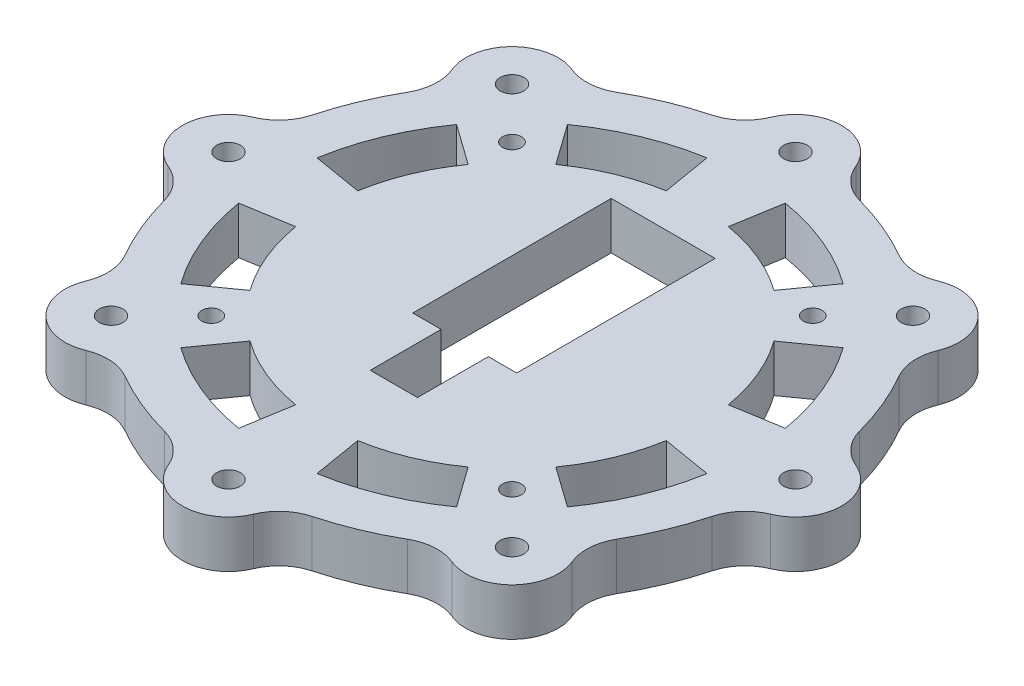
from build123d import *

# Parameters (mm, degrees)
CROQUIS1_W              = 22
CROQUIS1_H              = 42
CROQUIS1_R              = 2.5
CROQUIS1_R_2            = 2
SALIENTE_EXTRUIR1_DEPTH = 10
REDONDEO1_R             = 10
CROQUIS2_R              = 5
CORTAR_EXTRUIR1_DEPTH   = 5
CROQUIS3_W              = 10
CROQUIS3_H              = 15
CORTAR_EXTRUIR2_DEPTH   = 10


with BuildPart() as part:
    # Croquis1 → Saliente-Extruir1 (new body)
    with BuildSketch(Plane(origin=(0, 0, 0), x_dir=(1, 0, 0), z_dir=(0, 1, 0))):
        with BuildLine():
            ThreePointArc((-34.99474883, -48.737742606), (-22.961005942, -55.432771951), (-9.717764093, -59.2078125))
            ThreePointArc((-9.717764093, -59.2078125), (0, -69.75), (9.717764093, -59.2078125))
            ThreePointArc((9.717764093, -59.2078125), (22.961005942, -55.432771951), (34.99474883, -48.737742606))
            ThreePointArc((34.99474883, -48.737742606), (49.320697988, -49.320697988), (48.737742606, -34.99474883))
            ThreePointArc((48.737742606, -34.99474883), (55.432771951, -22.961005942), (59.2078125, -9.717764093))
            ThreePointArc((59.2078125, -9.717764093), (69.75, 0), (59.2078125, 9.717764093))
            ThreePointArc((59.2078125, 9.717764093), (55.432771951, 22.961005942), (48.737742606, 34.99474883))
            ThreePointArc((48.737742606, 34.99474883), (49.320697988, 49.320697988), (34.99474883, 48.737742606))
            ThreePointArc((34.99474883, 48.737742606), (22.961005942, 55.432771951), (9.717764093, 59.2078125))
            ThreePointArc((9.717764093, 59.2078125), (0, 69.75), (-9.717764093, 59.2078125))
            ThreePointArc((-9.717764093, 59.2078125), (-22.961005942, 55.432771951), (-34.99474883, 48.737742606))
            ThreePointArc((-34.99474883, 48.737742606), (-49.320697988, 49.320697988), (-48.737742606, 34.99474883))
            ThreePointArc((-48.737742606, 34.99474883), (-55.432771951, 22.961005942), (-59.2078125, 9.717764093))
            ThreePointArc((-59.2078125, 9.717764093), (-69.75, 0), (-59.2078125, -9.717764093))
            ThreePointArc((-59.2078125, -9.717764093), (-55.432771951, -22.961005942), (-48.737742606, -34.99474883))
            ThreePointArc((-48.737742606, -34.99474883), (-49.320697988, -49.320697988), (-34.99474883, -48.737742606))
        make_face()
        with Locations((0, 11)):
            Rectangle(CROQUIS1_W, CROQUIS1_H, mode=Mode.SUBTRACT)
        with BuildLine():
            Line((6.560642333, 39.204852661), (8.293642194, 49.560851477))
            ThreePointArc((8.293642194, 49.560851477), (19.229842476, 46.424946509), (29.180323524, 40.909304797))
            Line((29.180323524, 40.909304797), (23.08294249, 32.361091855))
            ThreePointArc((23.08294249, 32.361091855), (15.211666437, 36.724211417), (6.560642333, 39.204852661))
        make_face(mode=Mode.SUBTRACT)
        with BuildLine():
            Line((-8.293642194, 49.560851477), (-6.560642333, 39.204852661))
            ThreePointArc((-6.560642333, 39.204852661), (-15.211666437, 36.724211417), (-23.08294249, 32.361091855))
            Line((-23.08294249, 32.361091855), (-29.180323524, 40.909304797))
            ThreePointArc((-29.180323524, 40.909304797), (-19.229842476, 46.424946509), (-8.293642194, 49.560851477))
        make_face(mode=Mode.SUBTRACT)
        with BuildLine():
            Line((-40.909304797, 29.180323524), (-32.361091855, 23.08294249))
            ThreePointArc((-32.361091855, 23.08294249), (-36.724211417, 15.211666437), (-39.204852661, 6.560642333))
            Line((-39.204852661, 6.560642333), (-49.560851477, 8.293642194))
            ThreePointArc((-49.560851477, 8.293642194), (-46.424946509, 19.229842476), (-40.909304797, 29.180323524))
        make_face(mode=Mode.SUBTRACT)
        with Locations((-42.426406871, -42.426406871)):
            Circle(CROQUIS1_R, mode=Mode.SUBTRACT)
        with Locations((-42.426406871, 42.426406871)):
            Circle(CROQUIS1_R, mode=Mode.SUBTRACT)
        with Locations((-60, 0)):
            Circle(CROQUIS1_R, mode=Mode.SUBTRACT)
        with Locations((0, -60)):
            Circle(CROQUIS1_R, mode=Mode.SUBTRACT)
        with Locations((42.426406871, -42.426406871)):
            Circle(CROQUIS1_R, mode=Mode.SUBTRACT)
        with Locations((60, 0)):
            Circle(CROQUIS1_R, mode=Mode.SUBTRACT)
        with Locations((42.426406871, 42.426406871)):
            Circle(CROQUIS1_R, mode=Mode.SUBTRACT)
        with Locations((0, 60)):
            Circle(CROQUIS1_R, mode=Mode.SUBTRACT)
        with BuildLine():
            Line((-49.560851477, -8.293642194), (-39.204852661, -6.560642333))
            ThreePointArc((-39.204852661, -6.560642333), (-36.724211417, -15.211666437), (-32.361091855, -23.08294249))
            Line((-32.361091855, -23.08294249), (-40.909304797, -29.180323524))
            ThreePointArc((-40.909304797, -29.180323524), (-46.424946509, -19.229842476), (-49.560851477, -8.293642194))
        make_face(mode=Mode.SUBTRACT)
        with BuildLine():
            Line((-29.180323524, -40.909304797), (-23.08294249, -32.361091855))
            ThreePointArc((-23.08294249, -32.361091855), (-15.211666437, -36.724211417), (-6.560642333, -39.204852661))
            Line((-6.560642333, -39.204852661), (-8.293642194, -49.560851477))
            ThreePointArc((-8.293642194, -49.560851477), (-19.229842476, -46.424946509), (-29.180323524, -40.909304797))
        make_face(mode=Mode.SUBTRACT)
        with BuildLine():
            Line((8.293642194, -49.560851477), (6.560642333, -39.204852661))
            ThreePointArc((6.560642333, -39.204852661), (15.211666437, -36.724211417), (23.08294249, -32.361091855))
            Line((23.08294249, -32.361091855), (29.180323524, -40.909304797))
            ThreePointArc((29.180323524, -40.909304797), (19.229842476, -46.424946509), (8.293642194, -49.560851477))
        make_face(mode=Mode.SUBTRACT)
        with BuildLine():
            Line((40.909304797, -29.180323524), (32.361091855, -23.08294249))
            ThreePointArc((32.361091855, -23.08294249), (36.724211417, -15.211666437), (39.204852661, -6.560642333))
            Line((39.204852661, -6.560642333), (49.560851477, -8.293642194))
            ThreePointArc((49.560851477, -8.293642194), (46.424946509, -19.229842476), (40.909304797, -29.180323524))
        make_face(mode=Mode.SUBTRACT)
        with BuildLine():
            Line((49.560851477, 8.293642194), (39.204852661, 6.560642333))
            ThreePointArc((39.204852661, 6.560642333), (36.724211417, 15.211666437), (32.361091855, 23.08294249))
            Line((32.361091855, 23.08294249), (40.909304797, 29.180323524))
            ThreePointArc((40.909304797, 29.180323524), (46.424946509, 19.229842476), (49.560851477, 8.293642194))
        make_face(mode=Mode.SUBTRACT)
        with Locations((31.819805153, 31.819805153)):
            Circle(CROQUIS1_R_2, mode=Mode.SUBTRACT)
        with Locations((31.819805153, -31.819805153)):
            Circle(CROQUIS1_R_2, mode=Mode.SUBTRACT)
        with Locations((-31.819805153, -31.819805153)):
            Circle(CROQUIS1_R_2, mode=Mode.SUBTRACT)
        with Locations((-31.819805153, 31.819805153)):
            Circle(CROQUIS1_R_2, mode=Mode.SUBTRACT)
    extrude(amount=SALIENTE_EXTRUIR1_DEPTH)

    # Redondeo1
    redondeo1_edges = [part.edges().sort_by_distance(p)[0] for p in [
        (-59.2078125, 5, -9.717764093),
        (-48.737742606, 5, -34.99474883),
        (-34.99474883, 5, -48.737742606),
        (-9.717764093, 5, -59.2078125),
        (9.717764093, 5, -59.2078125),
        (34.99474883, 5, -48.737742606),
        (48.737742606, 5, -34.99474883),
        (59.2078125, 5, -9.717764093),
        (59.2078125, 5, 9.717764093),
        (48.737742606, 5, 34.99474883),
        (34.99474883, 5, 48.737742606),
        (9.717764093, 5, 59.2078125),
        (-9.717764093, 5, 59.2078125),
        (-34.99474883, 5, 48.737742606),
        (-48.737742606, 5, 34.99474883),
        (-59.2078125, 5, 9.717764093),
    ]]
    fillet(redondeo1_edges, radius=REDONDEO1_R)

    # Croquis2 → Cortar-Extruir1 (cut)
    with BuildSketch(Plane.XZ):
        with Locations((31.819805153, 31.819805153)):
            Circle(CROQUIS2_R)
        with Locations((31.819805153, -31.819805153)):
            Circle(CROQUIS2_R)
        with Locations((-31.819805153, -31.819805153)):
            Circle(CROQUIS2_R)
        with Locations((-31.819805153, 31.819805153)):
            Circle(CROQUIS2_R)
    extrude(amount=-CORTAR_EXTRUIR1_DEPTH, mode=Mode.SUBTRACT)

    # Croquis3 → Cortar-Extruir2 (cut)
    with BuildSketch(Plane(origin=(0, 10, 0), x_dir=(1, 0, 0), z_dir=(0, 1, 0))):
        with Locations((0, -17.5)):
            Rectangle(CROQUIS3_W, CROQUIS3_H)
    extrude(amount=-CORTAR_EXTRUIR2_DEPTH, mode=Mode.SUBTRACT)


solid = part.part
